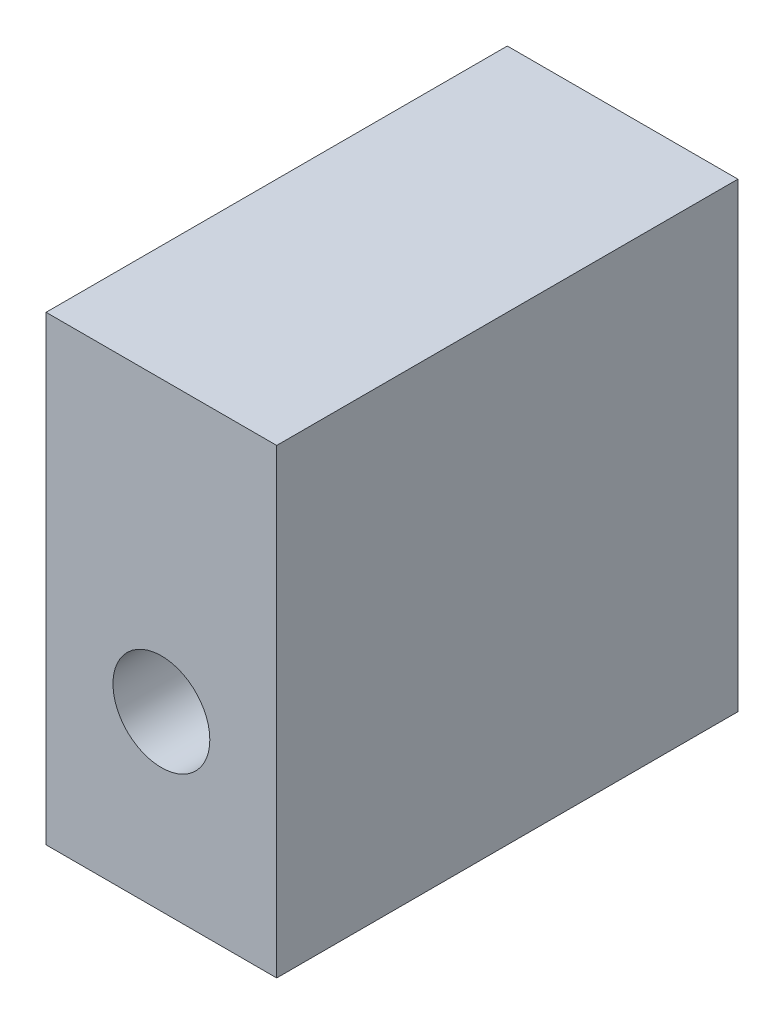
from build123d import *

# Parameters (mm, degrees)
SKETCH1_W               = 50.8
SKETCH1_H               = 101.6
BOSS_EXTRUDE2_DEPTH     = 101.6
SKETCH4_R               = 10.668
CUT_EXTRUDE2_DEPTH      = 51.8
CUT_EXTRUDE2_DEPTH_BACK = 51.8


with BuildPart() as part:
    # Sketch1 → Boss-Extrude2 (new body)
    with BuildSketch(Plane(origin=(0, 0, 0), x_dir=(1, 0, 0), z_dir=(0, 1, 0))):
        Rectangle(SKETCH1_W, SKETCH1_H)
    extrude(amount=BOSS_EXTRUDE2_DEPTH)

    # Sketch4 → Cut-Extrude2 (cut, two sides)
    with BuildSketch(Plane.XY) as cut_extrude2_sk:
        with Locations((0, 38.1)):
            Circle(SKETCH4_R)
    extrude(amount=CUT_EXTRUDE2_DEPTH, mode=Mode.SUBTRACT)
    extrude(cut_extrude2_sk.sketch, amount=-CUT_EXTRUDE2_DEPTH_BACK, mode=Mode.SUBTRACT)


solid = part.part
